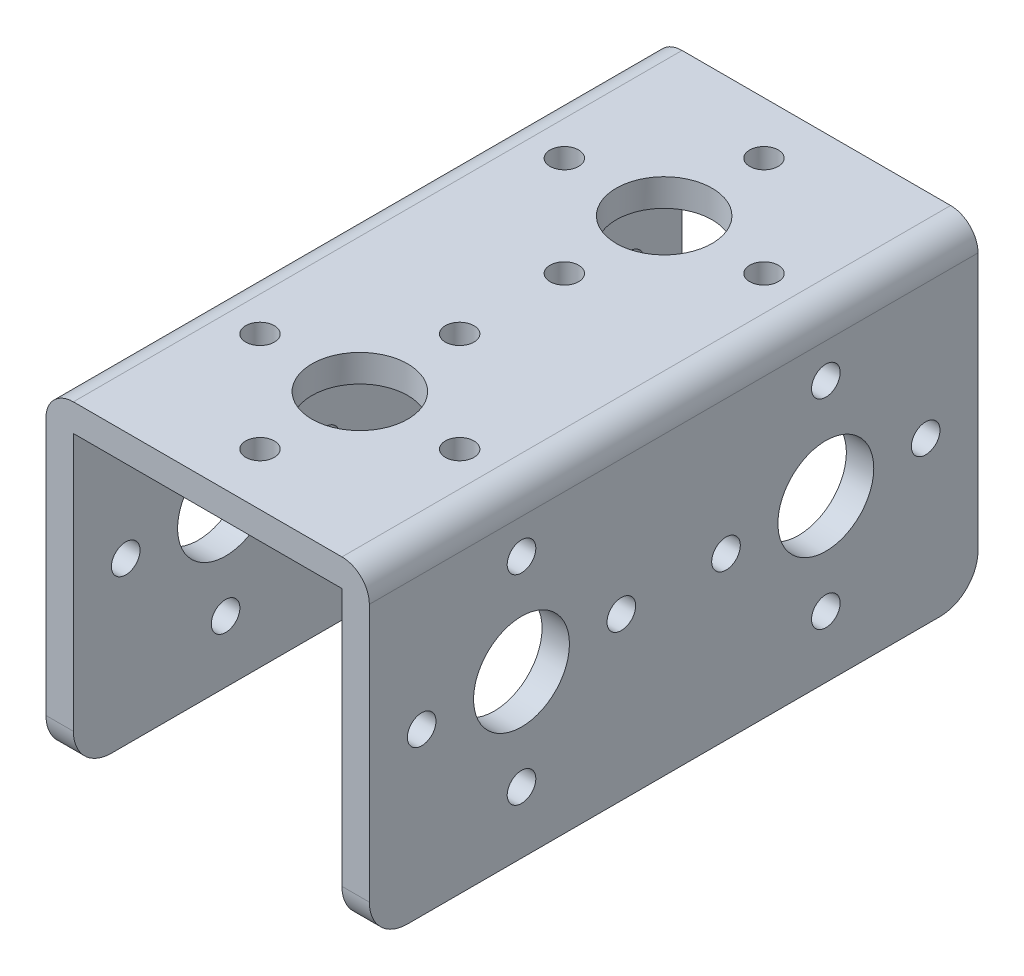
from build123d import *

# Parameters (mm, degrees)
EXTRUDE1_DEPTH      = 50.8
SKETCH2_R           = 4.0005
SKETCH2_R_2         = 1.1938
CUT_EXTRUDE1_DEPTH  = 27.9875
SKETCH22_R          = 4.0005
SKETCH22_R_2        = 1.1938
CUT_EXTRUDE12_DEPTH = 27.9875
LPATTERN1_COUNT     = 2
LPATTERN1_PITCH     = 25.4
FILLET1_R           = 2.286
FILLET2_R           = 3.175


with BuildPart() as part:
    # Sketch1 → Extrude1 (new body)
    with BuildSketch(Plane.XY):
        Polygon((11.20775, -26.9875), (11.20775, -2.286), (-11.20775, -2.286), (-11.20775, -26.9875), (-13.49375, -26.9875), (-13.49375, 0), (13.49375, 0), (13.49375, -26.9875), align=None)
    extrude(amount=-EXTRUDE1_DEPTH)

    # Sketch2 → Cut-Extrude1 (cut, through all)
    with BuildSketch(Plane(origin=(13.49375, -15.292465387, -16.409839131), x_dir=(0, 0, -1), z_dir=(1, 0, 0))):
        with Locations((-3.709839131, 1.792365387)):
            Circle(SKETCH2_R)
        with Locations((-3.709839131, 10.123565387)):
            Circle(SKETCH2_R_2)
        with Locations((4.621360869, 1.792365387)):
            Circle(SKETCH2_R_2)
        with Locations((-3.709839131, -6.538834613)):
            Circle(SKETCH2_R_2)
        with Locations((-12.041039131, 1.792365387)):
            Circle(SKETCH2_R_2)
    cut_extrude1 = extrude(amount=-CUT_EXTRUDE1_DEPTH, mode=Mode.SUBTRACT)

    # Sketch22 → Cut-Extrude12 (cut, through all)
    with BuildSketch(Plane(origin=(-3.640346977, 0, -15.26070859), x_dir=(-1, 0, 0), z_dir=(0, 1, 0))):
        with Locations(Location((-3.640346977, 2.56070859, 0), (0, 0, 90))):  # turned: the seam where the file's is
            Circle(SKETCH22_R)
        with Locations(Location((-3.640346977, 10.89190859, 0), (0, 0, 90))):  # turned: the seam where the file's is
            Circle(SKETCH22_R_2)
        with Locations(Location((4.690853023, 2.56070859, 0), (0, 0, 90))):  # turned: the seam where the file's is
            Circle(SKETCH22_R_2)
        with Locations(Location((-3.640346977, -5.77049141, 0), (0, 0, 90))):  # turned: the seam where the file's is
            Circle(SKETCH22_R_2)
        with Locations(Location((-11.971546977, 2.56070859, 0), (0, 0, 90))):  # turned: the seam where the file's is
            Circle(SKETCH22_R_2)
    cut_extrude12 = extrude(amount=-CUT_EXTRUDE12_DEPTH, mode=Mode.SUBTRACT)

    # LPattern1: Cut-Extrude1, Cut-Extrude12 ×2
    with Locations(*[(0, 0, -i * LPATTERN1_PITCH) for i in range(1, LPATTERN1_COUNT)]):
        add(cut_extrude1, mode=Mode.SUBTRACT)
        add(cut_extrude12, mode=Mode.SUBTRACT)

    # Fillet1
    fillet1_edges = [part.edges().sort_by_distance(p)[0] for p in [
        (-13.49375, 0, -25.4),
        (13.49375, 0, -25.4),
    ]]
    fillet(fillet1_edges, radius=FILLET1_R)

    # Fillet2
    fillet2_edges = [part.edges().sort_by_distance(p)[0] for p in [
        (12.35075, -26.9875, -50.8),
        (-12.35075, -26.9875, -50.8),
        (12.35075, -26.9875, 0),
        (-12.35075, -26.9875, 0),
    ]]
    fillet(fillet2_edges, radius=FILLET2_R)


solid = part.part
